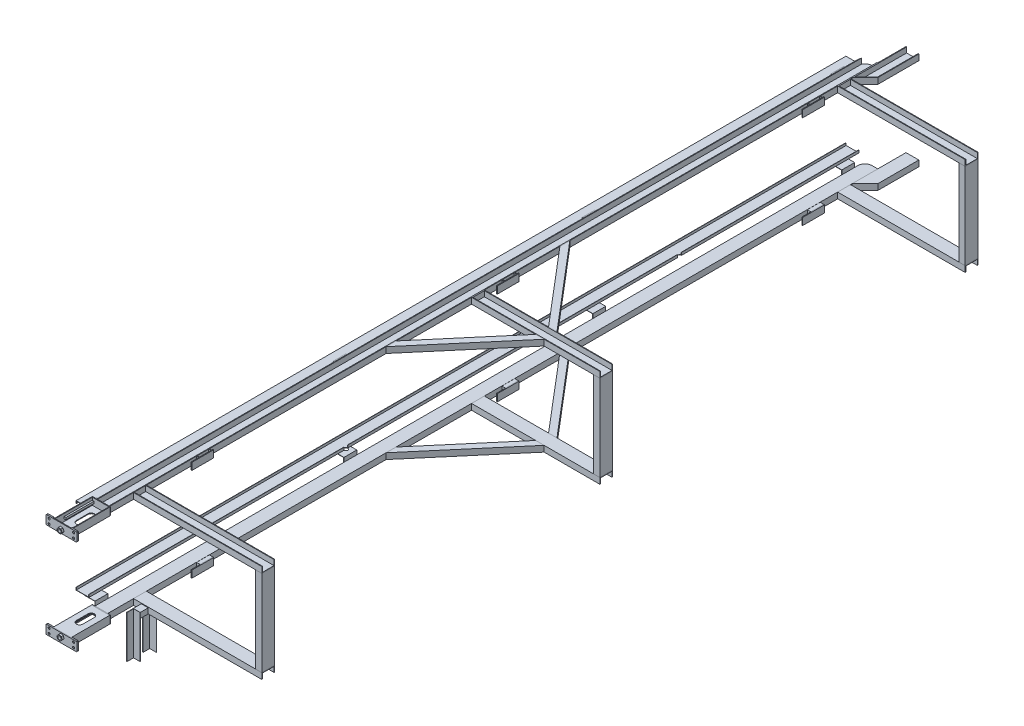
from build123d import *

# Parameters (mm, degrees)
BOSS_EXTRUDE1_DEPTH    = 3000
SKETCH24_W             = 1000
SKETCH24_H             = 100
BOSS_EXTRUDE10_DEPTH   = 46
BOSS_EXTRUDE10_2_DEPTH = 46
SKETCH24_W_2           = 993.755347339
BOSS_EXTRUDE10_3_DEPTH = 46
SHELL1_T               = -5
SHELL2_T               = -5
SKETCH31_W             = 27.98700134
SKETCH31_H             = 100
BOSS_EXTRUDE15_DEPTH   = 45
SHELL4_T               = -5
SKETCH33_W             = 170
SKETCH33_H             = 55
BOSS_EXTRUDE23_DEPTH   = 6
LPATTERN2_COUNT        = 3
LPATTERN2_PITCH        = 2380
SKETCH34_W             = 140
SKETCH34_H             = 60
BOSS_EXTRUDE25_DEPTH   = 6
BOSS_EXTRUDE26_DEPTH   = 300
SKETCH36_W             = 13
SKETCH36_H             = 16
BOSS_EXTRUDE27_DEPTH   = 220
BOSS_EXTRUDE27_2_DEPTH = 220
SKETCH37_W             = 240
SKETCH37_H             = 70
SKETCH37_R             = 8
BOSS_EXTRUDE28_DEPTH   = 6
SKETCH39_R             = 13
CUT_EXTRUDE3_DEPTH     = 6
BOSS_EXTRUDE31_DEPTH   = 46
SHELL6_T               = -5
CUT_EXTRUDE4_DEPTH     = 16
SKETCH57_W             = 6
SKETCH57_H             = 70
BOSS_EXTRUDE44_DEPTH   = 50
SKETCH58_R             = 8
CUT_EXTRUDE6_DEPTH     = 50
SHELL7_T               = -5
CUT_EXTRUDE7_DEPTH     = 76.5
SKETCH59_W             = 50
SKETCH59_H             = 70
SKETCH59_R             = 8
BOSS_EXTRUDE45_DEPTH   = 6
FILLET1_R              = 5
FILLET2_R              = 5
FILLET3_R              = 5
BOSS_EXTRUDE46_DEPTH   = 46
BOSS_EXTRUDE46_2_DEPTH = 46
SKETCH61_R             = 13
BOSS_EXTRUDE47_DEPTH   = 15
BOSS_EXTRUDE47_2_DEPTH = 15
SKETCH63_W             = 50
SKETCH63_H             = 100
BOSS_EXTRUDE48_DEPTH   = 670
BOSS_EXTRUDE48_2_DEPTH = 670
BOSS_EXTRUDE48_3_DEPTH = 670
BOSS_EXTRUDE49_DEPTH   = 3000
BOSS_EXTRUDE50_DEPTH   = 100
LPATTERN3_COUNT        = 4
LPATTERN3_PITCH        = 1940
SKETCH66_R             = 15
CUT_EXTRUDE8_DEPTH     = 1459
BOSS_EXTRUDE51_DEPTH   = 331.8
BOSS_EXTRUDE51_2_DEPTH = 331.8
SKETCH68_W             = 54.226955003
SKETCH68_H             = 41
BOSS_EXTRUDE52_DEPTH   = 60.336522498


with BuildPart() as part:
    # Sketch12 → Boss-Extrude1 (new, symmetric)
    with BuildSketch(Plane.XY):
        Polygon((-50, 0), (50, 0), (50, 46), (45, 46), (45, 5), (-45, 5), (-45, 46), (-50, 46), align=None)
    extrude(amount=BOSS_EXTRUDE1_DEPTH, both=True)

    # Sketch46 → Cut-Extrude7 (cut, symmetric)
    with BuildSketch(Plane(origin=(0, 5, 0), x_dir=(1, 0, 0), z_dir=(0, 1, 0))):
        with BuildLine():
            Line((-50, 2945.886432307), (-52.793998341, 2945.886432307))
            Line((-52.793998341, 2945.886432307), (-52.793998341, 3001.451310565))
            Line((-52.793998341, 3001.451310565), (4.113567693, 3001.451310565))
            Line((4.113567693, 3001.451310565), (4.113567693, 3000))
            ThreePointArc((4.113567693, 3000), (-34.150502977, 2984.150502977), (-50, 2945.886432307))
        make_face()
    extrude(amount=CUT_EXTRUDE7_DEPTH, both=True, mode=Mode.SUBTRACT)


with BuildPart() as body_2:
    # Sketch24 → Boss-Extrude10 (new body)
    with BuildSketch(Plane(origin=(0, 46, 0), x_dir=(1, 0, 0), z_dir=(0, 1, 0))):
        with Locations((550, -2750)):
            Rectangle(SKETCH24_W, SKETCH24_H)
    extrude(amount=-BOSS_EXTRUDE10_DEPTH)

    # Shell1
    shell1_openings = [body_2.faces().sort_by_distance(p)[0] for p in [
        (550, 46, 2750),
        (1050, 23, 2750),
        (50, 23, 2750),
    ]]
    offset(amount=SHELL1_T, openings=shell1_openings, kind=Kind.INTERSECTION)


with BuildPart() as body_3:
    # Sketch24 → Boss-Extrude10 2 (new body)
    with BuildSketch(Plane(origin=(0, 46, 0), x_dir=(1, 0, 0), z_dir=(0, 1, 0))):
        with Locations((550, -115.672019552)):
            Rectangle(SKETCH24_W, SKETCH24_H)
    extrude(amount=-BOSS_EXTRUDE10_2_DEPTH)

    # Shell2
    shell2_openings = [body_3.faces().sort_by_distance(p)[0] for p in [
        (550, 46, 115.672019552),
        (1050, 23, 115.672019552),
    ]]
    offset(amount=SHELL2_T, openings=shell2_openings, kind=Kind.INTERSECTION)


with BuildPart() as body_4:
    # Sketch24 → Boss-Extrude10 3 (new body)
    with BuildSketch(Plane(origin=(0, 46, 0), x_dir=(1, 0, 0), z_dir=(0, 1, 0))):
        with Locations((546.87767367, 2737.522014129)):
            Rectangle(SKETCH24_W_2, SKETCH24_H)
    extrude(amount=-BOSS_EXTRUDE10_3_DEPTH)

    # Shell7
    shell7_openings = [body_4.faces().sort_by_distance(p)[0] for p in [
        (546.87767367, 46, -2737.522014129),
        (1043.755347339, 23, -2737.522014129),
    ]]
    offset(amount=SHELL7_T, openings=shell7_openings, kind=Kind.INTERSECTION)


with BuildPart() as body_5:
    # Sketch31 → Boss-Extrude15 (new body)
    with BuildSketch(Plane(origin=(0, 46, 0), x_dir=(1, 0, 0), z_dir=(0, 1, 0))):
        with Locations((63.99350067, 2501.138441139)):
            Rectangle(SKETCH31_W, SKETCH31_H)
    extrude(amount=-BOSS_EXTRUDE15_DEPTH)

    # Shell4
    shell4_openings = [body_5.faces().sort_by_distance(p)[0] for p in [
        (63.99350067, 46, -2501.138441139),
        (77.98700134, 23.5, -2501.138441139),
        (50, 23.5, -2501.138441139),
    ]]
    offset(amount=SHELL4_T, openings=shell4_openings, kind=Kind.INTERSECTION)


with BuildPart() as body_6:
    # Sketch33 → Boss-Extrude23 (new body)
    with BuildSketch(Plane(origin=(77.98700134, 0, -5338.519788865), x_dir=(0, 0, 1), z_dir=(-1, 0, 0))):
        with Locations((2872.381347726, 28.5)):
            Rectangle(SKETCH33_W, SKETCH33_H)
    extrude(amount=-BOSS_EXTRUDE23_DEPTH)


with BuildPart() as lpattern2_1:
    # LPattern2: pattern copy
    add(body_5.part.moved(Location(Vector(0, 0, 1) * (1 * LPATTERN2_PITCH))))


with BuildPart() as lpattern2_2:
    # LPattern2: pattern copy
    add(body_5.part.moved(Location(Vector(0, 0, 1) * (2 * LPATTERN2_PITCH))))


with BuildPart() as lpattern2_3:
    # LPattern2: pattern copy
    add(body_6.part.moved(Location(Vector(0, 0, 1) * (1 * LPATTERN2_PITCH))))


with BuildPart() as lpattern2_4:
    # LPattern2: pattern copy
    add(body_6.part.moved(Location(Vector(0, 0, 1) * (2 * LPATTERN2_PITCH))))


with BuildPart() as body_11:
    # Sketch34 → Boss-Extrude25 (new body)
    with BuildSketch(Plane.XY.offset(3000)):
        with Locations((0, 30)):
            Rectangle(SKETCH34_W, SKETCH34_H)
    extrude(amount=BOSS_EXTRUDE25_DEPTH)


with BuildPart() as body_12:
    # Sketch35 → Boss-Extrude26 (new body)
    with BuildSketch(Plane.XY.offset(3006)):
        Polygon((70, 0), (70, 60), (65, 60), (65, 5), (-65, 5), (-65, 60), (-70, 60), (-70, 0), align=None)
    extrude(amount=BOSS_EXTRUDE26_DEPTH)

    # Sketch41 → Cut-Extrude4 (cut)
    with BuildSketch(Plane(origin=(0, 5, 0), x_dir=(1, 0, 0), z_dir=(0, 1, 0))):
        with BuildLine():
            Line((25, -3080), (25, -3170))
            ThreePointArc((25, -3170), (0, -3195), (-25, -3170))
            Line((-25, -3170), (-25, -3080))
            ThreePointArc((-25, -3080), (0, -3055), (25, -3080))
        make_face()
    extrude(amount=-CUT_EXTRUDE4_DEPTH, mode=Mode.SUBTRACT)


with BuildPart() as body_13:
    # Sketch36 → Boss-Extrude27 (new body)
    with BuildSketch(Plane.XY.offset(3006)):
        with Locations((-58.5, 31)):
            Rectangle(SKETCH36_W, SKETCH36_H)
    extrude(amount=BOSS_EXTRUDE27_DEPTH)


with BuildPart() as body_14:
    # Sketch36 → Boss-Extrude27 2 (new body)
    with BuildSketch(Plane.XY.offset(3006)):
        with Locations((58.5, 31)):
            Rectangle(SKETCH36_W, SKETCH36_H)
    extrude(amount=BOSS_EXTRUDE27_2_DEPTH)


with BuildPart() as body_15:
    # Sketch37 → Boss-Extrude28 (new body)
    with BuildSketch(Plane.XY.offset(3306)):
        with Locations((0, 35)):
            Rectangle(SKETCH37_W, SKETCH37_H)
        with Locations((-95.100711249, 53.457804047)):
            Circle(SKETCH37_R, mode=Mode.SUBTRACT)
        with Locations(Location((-95.100711249, 16.542195953, 0), (0, 0, 180))):
            Circle(SKETCH37_R, mode=Mode.SUBTRACT)
        with Locations((95.100711249, 16.542195953)):
            Circle(SKETCH37_R, mode=Mode.SUBTRACT)
        with Locations(Location((95.100711249, 53.457804047, 0), (0, 0, 180))):
            Circle(SKETCH37_R, mode=Mode.SUBTRACT)
    extrude(amount=BOSS_EXTRUDE28_DEPTH)

    # Sketch39 → Cut-Extrude3 (cut)
    with BuildSketch(Plane(origin=(0, 0, 3306), x_dir=(-1, 0, 0), z_dir=(0, 0, -1))):
        with Locations((0, 26)):
            Circle(SKETCH39_R)
    extrude(amount=-CUT_EXTRUDE3_DEPTH, mode=Mode.SUBTRACT)

    # Fillet1
    fillet1_edges = [body_15.edges().sort_by_distance(p)[0] for p in [
        (120, 70, 3309),
        (120, 0, 3309),
        (-120, 0, 3309),
        (-120, 70, 3309),
    ]]
    fillet(fillet1_edges, radius=FILLET1_R)


with BuildPart() as body_16:
    # Sketch43 → Boss-Extrude31 (new body)
    with BuildSketch(Plane(origin=(0, 46, 0), x_dir=(1, 0, 0), z_dir=(0, 1, 0))):
        Polygon((50, 2900.031254884), (50, 3220.031254884), (150, 3220.031254884), (150, 2900.031254884), (50, 2800.031254884), align=None)
    extrude(amount=-BOSS_EXTRUDE31_DEPTH)

    # Shell6
    shell6_openings = [body_16.faces().sort_by_distance(p)[0] for p in [
        (100, 23, -3220.031254884),
        (97.747747748, 46, -3033.905128758),
    ]]
    offset(amount=SHELL6_T, openings=shell6_openings, kind=Kind.INTERSECTION)


with BuildPart() as body_17:
    # Sketch57 → Boss-Extrude44 (new body)
    with BuildSketch(Plane.ZY.offset(70)):
        with Locations((3303, 35)):
            Rectangle(SKETCH57_W, SKETCH57_H)
    extrude(amount=BOSS_EXTRUDE44_DEPTH)

    # Sketch58 → Cut-Extrude6 (cut)
    with BuildSketch(Plane.XY.offset(3306)):
        with Locations((-95.100711249, 53.457804047)):
            Circle(SKETCH58_R)
        with Locations((-95.100711249, 16.542195953)):
            Circle(SKETCH58_R)
    extrude(amount=-CUT_EXTRUDE6_DEPTH, mode=Mode.SUBTRACT)

    # Fillet3
    fillet3_edges = [body_17.edges().sort_by_distance(p)[0] for p in [
        (-120, 0, 3303),
        (-120, 70, 3303),
    ]]
    fillet(fillet3_edges, radius=FILLET3_R)


with BuildPart() as body_18:
    # Sketch59 → Boss-Extrude45 (new body)
    with BuildSketch(Plane(origin=(0, 0, 3306), x_dir=(-1, 0, 0), z_dir=(0, 0, -1))):
        with Locations((-95, 35)):
            Rectangle(SKETCH59_W, SKETCH59_H)
        with Locations((-95.100711249, 16.542195953)):
            Circle(SKETCH59_R, mode=Mode.SUBTRACT)
        with Locations((-95.100711249, 53.457804047)):
            Circle(SKETCH59_R, mode=Mode.SUBTRACT)
    extrude(amount=BOSS_EXTRUDE45_DEPTH)

    # Fillet2
    fillet2_edges = [body_18.edges().sort_by_distance(p)[0] for p in [
        (120, 70, 3303),
        (120, 0, 3303),
    ]]
    fillet(fillet2_edges, radius=FILLET2_R)


with BuildPart() as body_19:
    # Sketch60 → Boss-Extrude46 (new body)
    with BuildSketch(Plane(origin=(0, 46, 0), x_dir=(1, 0, 0), z_dir=(0, 1, 0))):
        Polygon((50, 523.111164356), (550, -65.672019552), (615.596417333, -65.672019552), (50, 600.355299257), align=None)
    extrude(amount=-BOSS_EXTRUDE46_DEPTH)


with BuildPart() as body_20:
    # Sketch60 → Boss-Extrude46 2 (new body)
    with BuildSketch(Plane(origin=(0, 46, 0), x_dir=(1, 0, 0), z_dir=(0, 1, 0))):
        Polygon((50, -831.69933836), (50, -754.45520346), (550, -165.672019552), (615.596417333, -165.672019552), align=None)
    extrude(amount=-BOSS_EXTRUDE46_2_DEPTH)


with BuildPart() as body_21:
    # Mirror1: mirrored copy
    add(body_15.part.mirror(Plane(origin=(0, -335, 0), x_dir=(0, 0, 1), z_dir=(0, -1, 0))))


with BuildPart() as body_22:
    # Mirror1 2: mirrored copy
    add(body_17.part.mirror(Plane(origin=(0, -335, 0), x_dir=(0, 0, 1), z_dir=(0, -1, 0))))


with BuildPart() as body_23:
    # Mirror1 3: mirrored copy
    add(body_18.part.mirror(Plane(origin=(0, -335, 0), x_dir=(0, 0, 1), z_dir=(0, -1, 0))))


with BuildPart() as body_24:
    # Mirror1 4: mirrored copy
    add(body_12.part.mirror(Plane(origin=(0, -335, 0), x_dir=(0, 0, 1), z_dir=(0, -1, 0))))


with BuildPart() as body_25:
    # Mirror1 5: mirrored copy
    add(body_13.part.mirror(Plane(origin=(0, -335, 0), x_dir=(0, 0, 1), z_dir=(0, -1, 0))))


with BuildPart() as body_26:
    # Mirror1 6: mirrored copy
    add(body_14.part.mirror(Plane(origin=(0, -335, 0), x_dir=(0, 0, 1), z_dir=(0, -1, 0))))


with BuildPart() as body_27:
    # Mirror1 7: mirrored copy
    add(body_11.part.mirror(Plane(origin=(0, -335, 0), x_dir=(0, 0, 1), z_dir=(0, -1, 0))))


with BuildPart() as body_28:
    # Mirror1 8: mirrored copy
    add(part.part.mirror(Plane(origin=(0, -335, 0), x_dir=(0, 0, 1), z_dir=(0, -1, 0))))


with BuildPart() as body_29:
    # Mirror1 9: mirrored copy
    add(body_2.part.mirror(Plane(origin=(0, -335, 0), x_dir=(0, 0, 1), z_dir=(0, -1, 0))))


with BuildPart() as body_30:
    # Mirror1 10: mirrored copy
    add(lpattern2_2.part.mirror(Plane(origin=(0, -335, 0), x_dir=(0, 0, 1), z_dir=(0, -1, 0))))


with BuildPart() as body_31:
    # Mirror1 11: mirrored copy
    add(lpattern2_4.part.mirror(Plane(origin=(0, -335, 0), x_dir=(0, 0, 1), z_dir=(0, -1, 0))))


with BuildPart() as body_32:
    # Mirror1 12: mirrored copy
    add(body_3.part.mirror(Plane(origin=(0, -335, 0), x_dir=(0, 0, 1), z_dir=(0, -1, 0))))


with BuildPart() as body_33:
    # Mirror1 13: mirrored copy
    add(lpattern2_1.part.mirror(Plane(origin=(0, -335, 0), x_dir=(0, 0, 1), z_dir=(0, -1, 0))))


with BuildPart() as body_34:
    # Mirror1 14: mirrored copy
    add(lpattern2_3.part.mirror(Plane(origin=(0, -335, 0), x_dir=(0, 0, 1), z_dir=(0, -1, 0))))


with BuildPart() as body_35:
    # Mirror1 15: mirrored copy
    add(body_5.part.mirror(Plane(origin=(0, -335, 0), x_dir=(0, 0, 1), z_dir=(0, -1, 0))))


with BuildPart() as body_36:
    # Mirror1 16: mirrored copy
    add(body_6.part.mirror(Plane(origin=(0, -335, 0), x_dir=(0, 0, 1), z_dir=(0, -1, 0))))


with BuildPart() as body_37:
    # Mirror1 17: mirrored copy
    add(body_4.part.mirror(Plane(origin=(0, -335, 0), x_dir=(0, 0, 1), z_dir=(0, -1, 0))))


with BuildPart() as body_38:
    # Mirror1 18: mirrored copy
    add(body_16.part.mirror(Plane(origin=(0, -335, 0), x_dir=(0, 0, 1), z_dir=(0, -1, 0))))


with BuildPart() as body_39:
    # Mirror1 19: mirrored copy
    add(body_20.part.mirror(Plane(origin=(0, -335, 0), x_dir=(0, 0, 1), z_dir=(0, -1, 0))))


with BuildPart() as body_40:
    # Mirror1 20: mirrored copy
    add(body_19.part.mirror(Plane(origin=(0, -335, 0), x_dir=(0, 0, 1), z_dir=(0, -1, 0))))


with BuildPart() as body_41:
    # Sketch61 → Boss-Extrude47 (new body)
    with BuildSketch(Plane.XY.offset(3312)):
        Polygon((12.158048727, 43.211604061), (-8.826661993, 45.134981088), (-20.98471072, 27.923377027), (-12.158048727, 8.788395939), (8.826661993, 6.865018912), (20.98471072, 24.076622973), align=None)
        with Locations((0, 26)):
            Circle(SKETCH61_R, mode=Mode.SUBTRACT)
    extrude(amount=BOSS_EXTRUDE47_DEPTH)


with BuildPart() as body_42:
    # Sketch61 → Boss-Extrude47 2 (new body)
    with BuildSketch(Plane.XY.offset(3312)):
        Polygon((-20.528158483, -691.240570151), (-14.385866398, -711.398191815), (6.142292085, -716.157621664), (20.528158483, -700.759429849), (14.385866398, -680.601808185), (-6.142292085, -675.842378336), align=None)
        with Locations((0, -696)):
            Circle(SKETCH61_R, mode=Mode.SUBTRACT)
    extrude(amount=BOSS_EXTRUDE47_2_DEPTH)


with BuildPart() as body_43:
    # Sketch63 → Boss-Extrude48 (new body)
    with BuildSketch(Plane.XZ):
        with Locations((1018.755347339, -2737.522014129)):
            Rectangle(SKETCH63_W, SKETCH63_H)
    extrude(amount=BOSS_EXTRUDE48_DEPTH)


with BuildPart() as body_44:
    # Sketch63 → Boss-Extrude48 2 (new body)
    with BuildSketch(Plane.XZ):
        with Locations((1025, 115.672019552)):
            Rectangle(SKETCH63_W, SKETCH63_H)
    extrude(amount=BOSS_EXTRUDE48_2_DEPTH)


with BuildPart() as body_45:
    # Sketch63 → Boss-Extrude48 3 (new body)
    with BuildSketch(Plane.XZ):
        with Locations((1025, 2750)):
            Rectangle(SKETCH63_W, SKETCH63_H)
    extrude(amount=BOSS_EXTRUDE48_3_DEPTH)


with BuildPart() as body_46:
    # Sketch64 → Boss-Extrude49 (new, symmetric)
    with BuildSketch(Plane.XY):
        Polygon((-100, -53), (-100, -35), (-196, -35), (-196, -53), (-198, -53), (-198, -33), (-98, -33), (-98, -53), align=None)
    extrude(amount=BOSS_EXTRUDE49_DEPTH, both=True)


with BuildPart() as body_47:
    # Sketch65 → Boss-Extrude50 (new body)
    with BuildSketch(Plane.XY.offset(3000)):
        Polygon((-50, 29.404605041), (-50, 0), (-50, -33), (-135.148139065, -33), (-135.148139065, -31), (-52, -31), (-52, 0), (-52, 29.404605041), align=None)
    extrude(amount=-BOSS_EXTRUDE50_DEPTH)


with BuildPart() as lpattern3_1:
    # LPattern3: pattern copy
    add(body_47.part.moved(Location(Vector(0, 0, -1) * (1 * LPATTERN3_PITCH))))


with BuildPart() as lpattern3_2:
    # LPattern3: pattern copy
    add(body_47.part.moved(Location(Vector(0, 0, -1) * (2 * LPATTERN3_PITCH))))


with BuildPart() as lpattern3_3:
    # LPattern3: pattern copy
    add(body_47.part.moved(Location(Vector(0, 0, -1) * (3 * LPATTERN3_PITCH))))


with BuildPart() as body_51:
    # Mirror2: mirrored copy
    add(lpattern3_3.part.mirror(Plane(origin=(0, -335, 0), x_dir=(0, 0, 1), z_dir=(0, -1, 0))))


with BuildPart() as body_52:
    # Mirror2 2: mirrored copy
    add(body_46.part.mirror(Plane(origin=(0, -335, 0), x_dir=(0, 0, 1), z_dir=(0, -1, 0))))


with BuildPart() as body_53:
    # Mirror2 3: mirrored copy
    add(lpattern3_2.part.mirror(Plane(origin=(0, -335, 0), x_dir=(0, 0, 1), z_dir=(0, -1, 0))))


with BuildPart() as body_54:
    # Mirror2 4: mirrored copy
    add(body_47.part.mirror(Plane(origin=(0, -335, 0), x_dir=(0, 0, 1), z_dir=(0, -1, 0))))


with BuildPart() as body_55:
    # Mirror2 5: mirrored copy
    add(lpattern3_1.part.mirror(Plane(origin=(0, -335, 0), x_dir=(0, 0, 1), z_dir=(0, -1, 0))))


with BuildPart() as cut_extrude8_tool:
    # Sketch66 → Cut-Extrude8 (new body)
    with BuildSketch(Plane(origin=(0, -33, 0), x_dir=(1, 0, 0), z_dir=(0, 1, 0))):
        with Locations(Location((-98, -996.97, 0), (0, 0, 180))):
            Circle(SKETCH66_R)
        with Locations((-98, 1603.03)):
            Circle(SKETCH66_R)
    extrude(amount=-CUT_EXTRUDE8_DEPTH)


with BuildPart() as body_46_1:
    add(body_46.part)

    # Cut-Extrude8: cut by cut_extrude8_tool
    add(cut_extrude8_tool.part, mode=Mode.SUBTRACT)


with BuildPart() as body_52_1:
    add(body_52.part)

    # Cut-Extrude8: cut by cut_extrude8_tool
    add(cut_extrude8_tool.part, mode=Mode.SUBTRACT)


with BuildPart() as body_55_1:
    add(body_55.part)

    # Cut-Extrude8: cut by cut_extrude8_tool
    add(cut_extrude8_tool.part, mode=Mode.SUBTRACT)


with BuildPart() as body_56:
    # Sketch67 → Boss-Extrude51 (new body)
    with BuildSketch(Plane.XZ.offset(675)):
        Polygon((110.5, 2734.336522498), (164.726955003, 2734.336522498), (164.726955003, 2737.336522498), (113.5, 2737.336522498), (113.5, 2788.563477502), (110.5, 2788.563477502), align=None)
    extrude(amount=BOSS_EXTRUDE51_DEPTH)


with BuildPart() as body_57:
    # Sketch67 → Boss-Extrude51 2 (new body)
    with BuildSketch(Plane.XZ.offset(675)):
        Polygon((113.5, 2863.336522498), (164.726955003, 2863.336522498), (164.726955003, 2860.336522498), (110.5, 2860.336522498), (110.5, 2914.563477502), (113.5, 2914.563477502), align=None)
    extrude(amount=BOSS_EXTRUDE51_2_DEPTH)


with BuildPart() as body_58:
    # Sketch68 → Boss-Extrude52 (new body)
    with BuildSketch(Plane.XY.offset(2800)):
        with Locations((137.613477502, -695.5)):
            Rectangle(SKETCH68_W, SKETCH68_H)
    extrude(amount=BOSS_EXTRUDE52_DEPTH)


solid = Compound([part.part, body_2.part, body_3.part, body_4.part, body_5.part, body_6.part, lpattern2_1.part, lpattern2_2.part, lpattern2_3.part, lpattern2_4.part, body_11.part, body_12.part, body_13.part, body_14.part, body_15.part, body_16.part, body_17.part, body_18.part, body_19.part, body_20.part, body_21.part, body_22.part, body_23.part, body_24.part, body_25.part, body_26.part, body_27.part, body_28.part, body_29.part, body_30.part, body_31.part, body_32.part, body_33.part, body_34.part, body_35.part, body_36.part, body_37.part, body_38.part, body_39.part, body_40.part, body_41.part, body_42.part, body_43.part, body_44.part, body_45.part, body_47.part, lpattern3_1.part, lpattern3_2.part, lpattern3_3.part, body_51.part, body_53.part, body_54.part, body_46_1.part, body_52_1.part, body_55_1.part, body_56.part, body_57.part, body_58.part])
